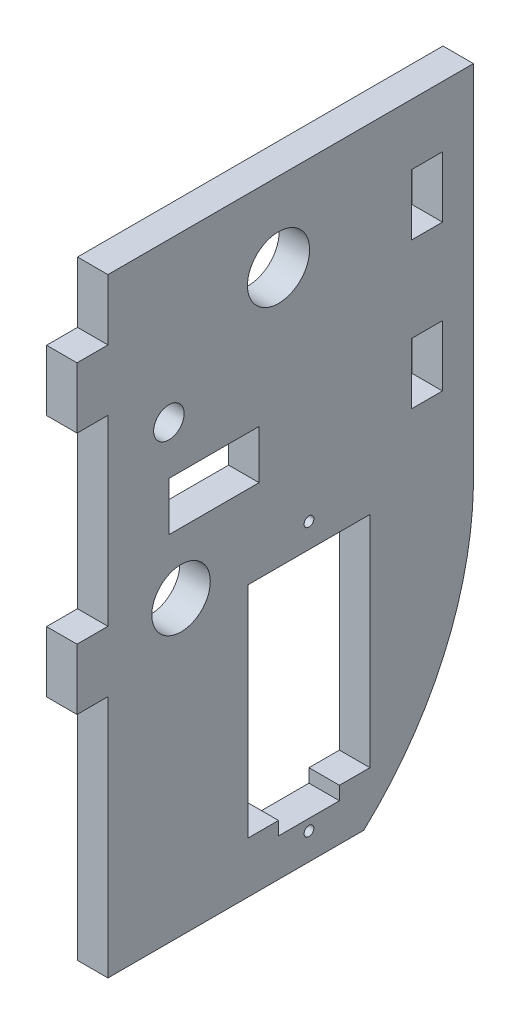
from build123d import *

# Parameters (mm, degrees)
SKETCH1_W                          = 38.1
SKETCH1_H                          = 63.5
MAIN_BODY_DEPTH                    = 3.175
SKETCH2_W                          = 3.2258
SKETCH2_H                          = 6.35
TABS_DEPTH                         = 3.175
SKETCH5_R                          = 0.508
MOTOR_CUT_DEPTH                    = 4.175
SKETCH6_R                          = 3.2385
CUT_FOR_AXLE_DEPTH                 = 4.175
ROUND_OFF_BACK_CORNER_DEPTH        = 4.175
SKETCH8_W                          = 3.2258
SKETCH8_H                          = 6.35
CUT_FOR_TABS_DEPTH                 = 4.175
SKETCH9_R                          = 1.5875
CUT_FOR_BRACKET_SCREW_DEPTH        = 4.175
SKETCH10_R                         = 3.048
CUT_FOR_BASIC_2ND_MOUNT_AXLE_DEPTH = 4.175
SKETCH11_W                         = 9.398
SKETCH11_H                         = 5.08
CUT_EXTRUDE1_DEPTH                 = 4.175


with BuildPart() as part:
    # Sketch1 → main body (new body)
    with BuildSketch(Plane(origin=(0, 0, 0), x_dir=(0, 0, -1), z_dir=(1, 0, 0))):
        Rectangle(SKETCH1_W, SKETCH1_H)
    extrude(amount=MAIN_BODY_DEPTH)

    # Sketch2 → tabs (add)
    with BuildSketch(Plane(origin=(3.175, 0, 0), x_dir=(0, 0, -1), z_dir=(1, 0, 0))):
        with Locations((-20.6629, 22.225)):
            Rectangle(SKETCH2_W, SKETCH2_H)
        with Locations((-20.6629, -3.175)):
            Rectangle(SKETCH2_W, SKETCH2_H)
    extrude(amount=-TABS_DEPTH)

    # Sketch5 → motor cut (cut, through all)
    with BuildSketch(Plane(origin=(3.175, 0, 0), x_dir=(0, 0, -1), z_dir=(1, 0, 0))):
        with Locations((1.905, -28.956)):
            Circle(SKETCH5_R)
        with Locations((1.905, -1.016)):
            Circle(SKETCH5_R)
        Polygon((8.255, -3.556), (-4.445, -3.556), (-4.445, -26.416), (-1.27, -26.416), (-1.27, -27.813), (5.08, -27.813), (5.08, -26.416), (8.255, -26.416), align=None)
    extrude(amount=-MOTOR_CUT_DEPTH, mode=Mode.SUBTRACT)

    # Sketch6 → cut for axle (cut, through all)
    with BuildSketch(Plane(origin=(3.175, 0, 0), x_dir=(0, 0, -1), z_dir=(1, 0, 0))):
        with Locations((-1.27, 23.495)):
            Circle(SKETCH6_R)
    extrude(amount=-CUT_FOR_AXLE_DEPTH, mode=Mode.SUBTRACT)

    # Sketch7 → round off back corner (cut, through all)
    with BuildSketch(Plane(origin=(3.175, 0, 0), x_dir=(0, 0, -1), z_dir=(1, 0, 0))):
        with BuildLine():
            Line((19.05, -31.75), (19.05, -6.35))
            ThreePointArc((19.05, -6.35), (15.925359096, -20.215661593), (7.62, -31.75))
            Line((7.62, -31.75), (19.05, -31.75))
        make_face()
    extrude(amount=-ROUND_OFF_BACK_CORNER_DEPTH, mode=Mode.SUBTRACT)

    # Sketch8 → cut for tabs (cut, through all)
    with BuildSketch(Plane(origin=(3.175, 0, 0), x_dir=(0, 0, -1), z_dir=(1, 0, 0))):
        with Locations((14.2113, 22.225)):
            Rectangle(SKETCH8_W, SKETCH8_H)
        with Locations((14.2113, 6.985)):
            Rectangle(SKETCH8_W, SKETCH8_H)
    extrude(amount=-CUT_FOR_TABS_DEPTH, mode=Mode.SUBTRACT)

    # Sketch9 → cut for bracket screw (cut, through all)
    with BuildSketch(Plane(origin=(3.175, 0, 0), x_dir=(0, 0, -1), z_dir=(1, 0, 0))):
        with Locations((-12.7, 15.24)):
            Circle(SKETCH9_R)
    extrude(amount=-CUT_FOR_BRACKET_SCREW_DEPTH, mode=Mode.SUBTRACT)

    # Sketch10 → cut for basic 2nd mount axle (cut, through all)
    with BuildSketch(Plane(origin=(3.175, 0, 0), x_dir=(0, 0, -1), z_dir=(1, 0, 0))):
        with Locations((-11.43, -1.27)):
            Circle(SKETCH10_R)
    extrude(amount=-CUT_FOR_BASIC_2ND_MOUNT_AXLE_DEPTH, mode=Mode.SUBTRACT)

    # Sketch11 → Cut-Extrude1 (cut, through all)
    with BuildSketch(Plane(origin=(3.175, 0, 0), x_dir=(0, 0, -1), z_dir=(1, 0, 0))):
        with Locations((-8.001, 7.630964138)):
            Rectangle(SKETCH11_W, SKETCH11_H)
    extrude(amount=-CUT_EXTRUDE1_DEPTH, mode=Mode.SUBTRACT)


solid = part.part
